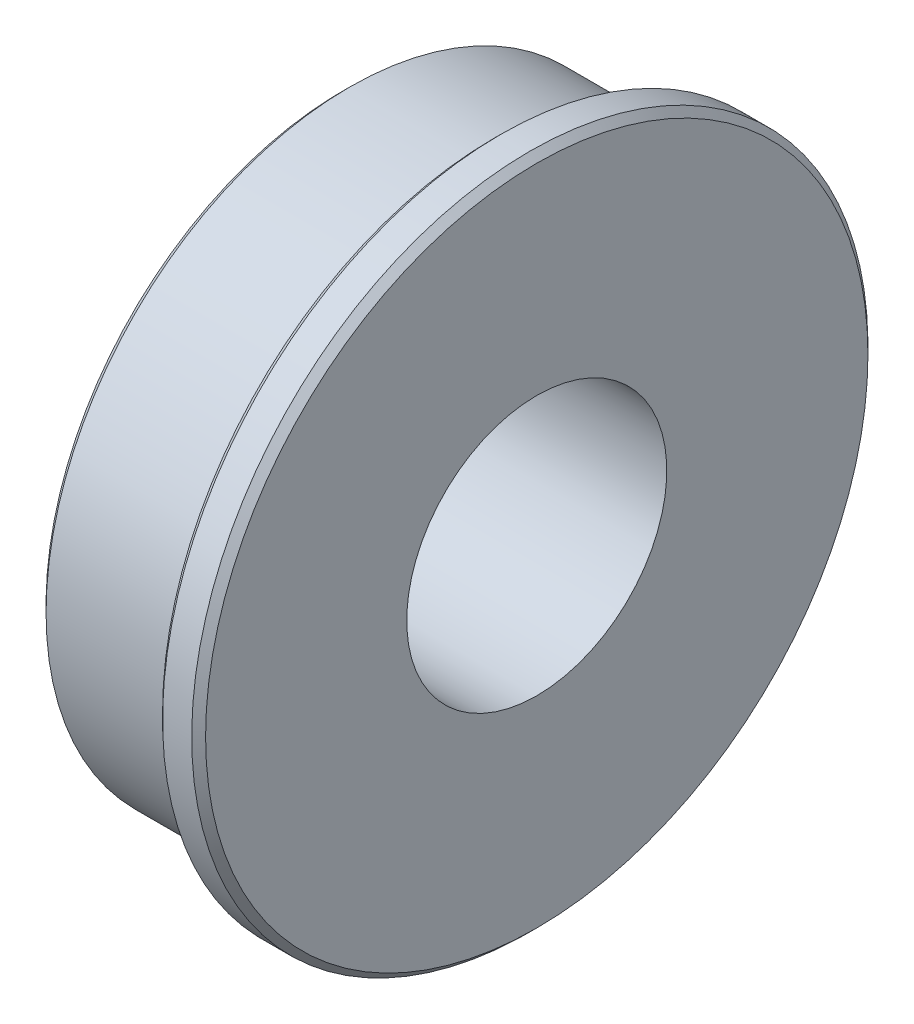
from build123d import *

# Parameters (mm, degrees)
CHAMFER1_SIZE = 0.254


with BuildPart() as part:
    # Sketch1 → Revolve1 (revolve)
    with BuildSketch(Plane.XY):
        Polygon((-3.556, 11.1125), (1.9812, 11.1125), (1.9812, 12.3825), (3.556, 12.3825), (3.556, 4.7625), (-3.556, 4.7625), align=None)
    revolve(axis=Axis((3.556, 0, 0), (-1, 0, 0)))

    # Chamfer1
    chamfer1_edges = [part.edges().sort_by_distance(p)[0] for p in [
        (-3.556, -11.1125, 0),
        (1.9812, -12.3825, 0),
        (3.556, -12.3825, 0),
    ]]
    chamfer(chamfer1_edges, length=CHAMFER1_SIZE)


solid = part.part
